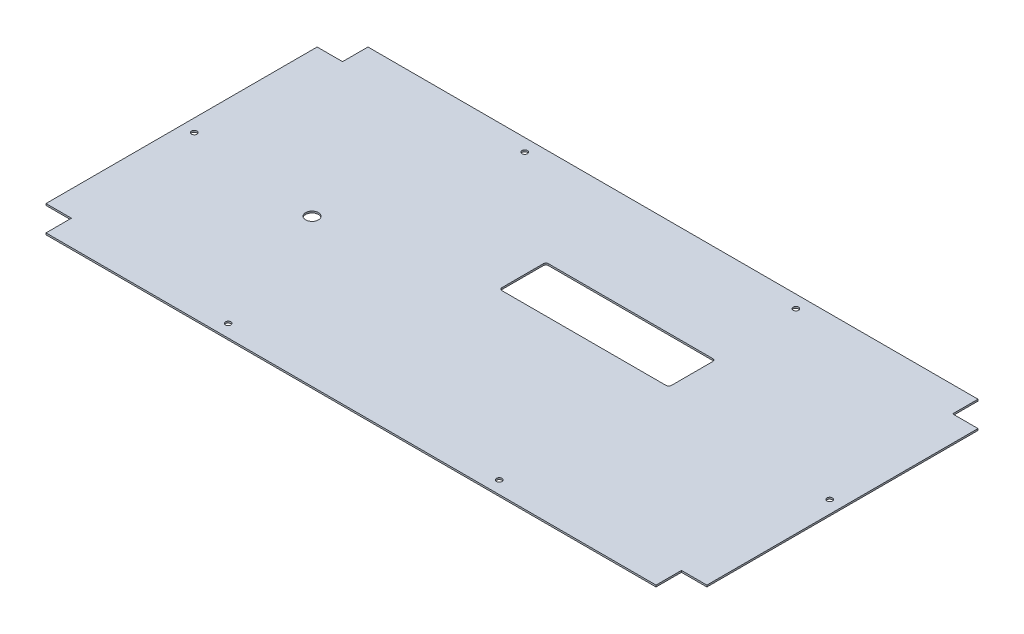
from build123d import *

# Parameters (mm, degrees)
SKETCH2_W           = 780
SKETCH2_H           = 380
BOSS_EXTRUDE1_DEPTH = 2
SKETCH3_W           = 30
SKETCH3_H           = 30
CUT_EXTRUDE1_DEPTH  = 3
SKETCH4_R           = 3.25
CUT_EXTRUDE2_DEPTH  = 3
SKETCH5_R           = 7.5
CUT_EXTRUDE3_DEPTH  = 3
CUT_EXTRUDE4_DEPTH  = 3


with BuildPart() as part:
    # Sketch2 → Boss-Extrude1 (new body)
    with BuildSketch(Plane(origin=(0, 0, 0), x_dir=(1, 0, 0), z_dir=(0, 1, 0))):
        Rectangle(SKETCH2_W, SKETCH2_H)
    extrude(amount=BOSS_EXTRUDE1_DEPTH)

    # Sketch3 → Cut-Extrude1 (cut, through all)
    with BuildSketch(Plane(origin=(0, 2, 0), x_dir=(1, 0, 0), z_dir=(0, 1, 0))):
        with Locations((-375, 175)):
            Rectangle(SKETCH3_W, SKETCH3_H)
        with Locations((375, 175)):
            Rectangle(SKETCH3_W, SKETCH3_H)
        with Locations((375, -175)):
            Rectangle(SKETCH3_W, SKETCH3_H)
        with Locations((-375, -175)):
            Rectangle(SKETCH3_W, SKETCH3_H)
    extrude(amount=-CUT_EXTRUDE1_DEPTH, mode=Mode.SUBTRACT)

    # Sketch4 → Cut-Extrude2 (cut, through all)
    with BuildSketch(Plane(origin=(0, 2, 0), x_dir=(1, 0, 0), z_dir=(0, 1, 0))):
        with Locations((-375, 0)):
            Circle(SKETCH4_R)
        with Locations((375, 0)):
            Circle(SKETCH4_R)
        with Locations((-160, 175)):
            Circle(SKETCH4_R)
        with Locations((160, 175)):
            Circle(SKETCH4_R)
        with Locations((-160, -175)):
            Circle(SKETCH4_R)
        with Locations((160, -175)):
            Circle(SKETCH4_R)
    extrude(amount=-CUT_EXTRUDE2_DEPTH, mode=Mode.SUBTRACT)

    # Sketch5 → Cut-Extrude3 (cut, through all)
    with BuildSketch(Plane(origin=(0, 2, 0), x_dir=(1, 0, 0), z_dir=(0, 1, 0))):
        with Locations((-220, -16)):
            Circle(SKETCH5_R)
    extrude(amount=-CUT_EXTRUDE3_DEPTH, mode=Mode.SUBTRACT)

    # Sketch6 → Cut-Extrude4 (cut, through all)
    with BuildSketch(Plane(origin=(0, 2, 0), x_dir=(1, 0, 0), z_dir=(0, 1, 0))):
        with BuildLine():
            Line((-32, 75), (162, 75))
            ThreePointArc((162, 75), (164.121320344, 74.121320344), (165, 72))
            Line((165, 72), (165, 23))
            ThreePointArc((165, 23), (164.121320344, 20.878679656), (162, 20))
            Line((162, 20), (-32, 20))
            ThreePointArc((-32, 20), (-34.121320344, 20.878679656), (-35, 23))
            Line((-35, 23), (-35, 72))
            ThreePointArc((-35, 72), (-34.121320344, 74.121320344), (-32, 75))
        make_face()
    extrude(amount=-CUT_EXTRUDE4_DEPTH, mode=Mode.SUBTRACT)


solid = part.part
